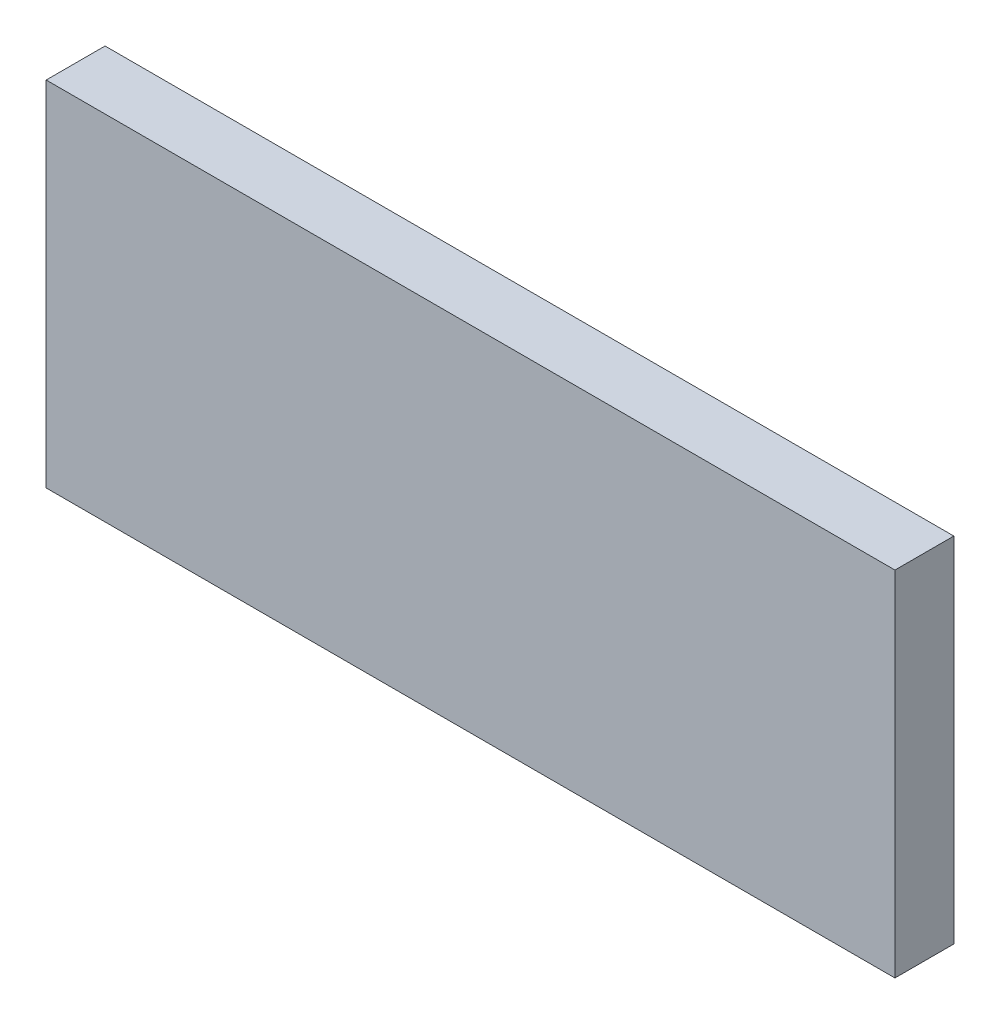
from build123d import *

# Parameters (mm, degrees)
SKETCH_1_W          = 72.07
SKETCH_1_H          = 5
EXTRUDE_1_DEPTH     = 30
CUT_EXTRUDE_1_DEPTH = 4
CUT_EXTRUDE_START   = -15
CUT_EXTRUDE_2_DEPTH = 10.25


with BuildPart() as part:
    # 草圖1 → 填料-伸長1 (new body)
    with BuildSketch(Plane(origin=(0, 0, 0), x_dir=(1, 0, 0), z_dir=(0, 1, 0))):
        Rectangle(SKETCH_1_W, SKETCH_1_H)
    extrude(amount=EXTRUDE_1_DEPTH)

    # 草圖2 → 除料-伸長1 (cut)
    with BuildSketch(Plane(origin=(0, 0, -2.5), x_dir=(-1, 0, 0), z_dir=(0, 0, -1))):
        Polygon((36.035, 19), (36.035, 11), (31.035, 11), (31.035, 9.75), (-1.465, 9.75), (-1.465, 20.25), (31.035, 20.25), (31.035, 19), align=None)
    extrude(amount=-CUT_EXTRUDE_1_DEPTH, mode=Mode.SUBTRACT)

    # 草圖3 → 除料-伸長2 (cut, symmetric)
    with BuildSketch(Plane(origin=(0, 30, 0), x_dir=(1, 0, 0), z_dir=(0, 1, 0)).offset(CUT_EXTRUDE_START)):
        Polygon((33.364978213, 2.5), (31.835, -0.15), (27.24506536, 2.5), align=None)
    extrude(amount=CUT_EXTRUDE_2_DEPTH, both=True, mode=Mode.SUBTRACT)


solid = part.part
